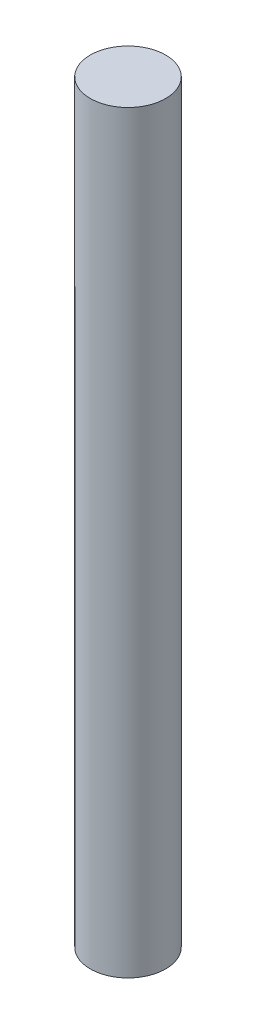
from build123d import *

# Parameters (mm, degrees)
SKETCH_1_W          = 7.5
SKETCH_1_H          = 150
CUT_EXTRUDE_1_DEPTH = 1


with BuildPart() as part:
    # 草图1 → 旋转1 (revolve)
    with BuildSketch(Plane.XY):
        Rectangle(SKETCH_1_W, SKETCH_1_H)
    revolve(axis=Axis((3.75, 75, 0), (0, -1, 0)))

    # 草图2 → 切除-拉伸1 (cut, symmetric)
    with BuildSketch(Plane.XY):
        Polygon((1.25, 69.5), (-3.75, 75), (-27.95, 75), (-27.95, -24), (-3.75, -24), (1.25, -18.5), (-3.75, -13), (1.25, -7.5), (-3.75, -2), (1.25, 3.5), (-3.75, 9), (1.25, 14.5), (-3.75, 20), (1.25, 25.5), (-3.75, 31), (1.25, 36.5), (-3.75, 42), (1.25, 47.5), (-3.75, 53), (1.25, 58.5), (-3.75, 64), align=None)
    extrude(amount=CUT_EXTRUDE_1_DEPTH, both=True, mode=Mode.SUBTRACT)


solid = part.part
